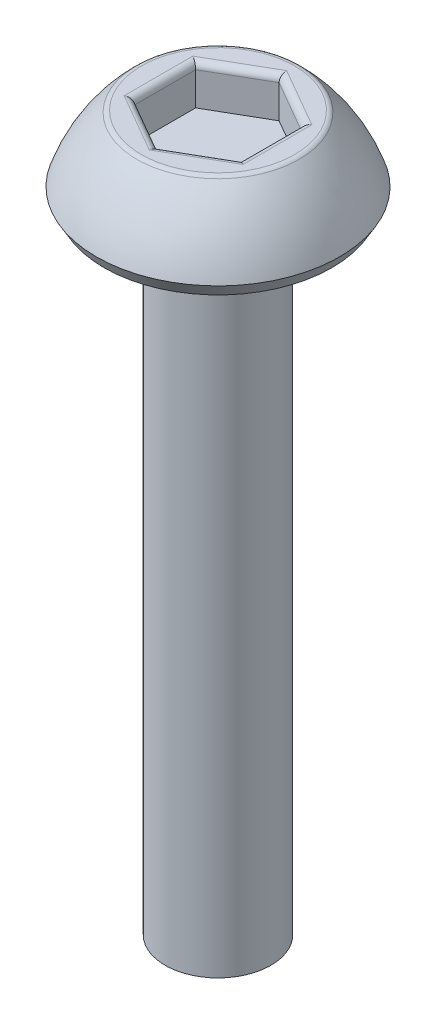
from build123d import *

# Parameters (mm, degrees)
CUT_EXTRUDE1_DEPTH = 0.75
FILLET1_R          = 0.125


with BuildPart() as part:
    # Sketch1 → Revolve1 (revolve)
    with BuildSketch(Plane(origin=(0, 0, 0), x_dir=(0, 0, -1), z_dir=(1, 0, 0))):
        with BuildLine():
            Line((0, 1.5), (-1.5, 1.5))
            ThreePointArc((-1.5, 1.5), (-1.978515811, 0.925250119), (-2.3, 0.25))
            Line((-2.3, 0.25), (-2.155662433, 0))
            Line((-2.155662433, 0), (-1, 0))
            Line((-1, 0), (-1, -12))
            Line((-1, -12), (0, -12))
            Line((0, -12), (0, 1.5))
        make_face()
    revolve(axis=Axis((0, -12, 0), (0, 1, 0)))

    # Sketch2 → Cut-Extrude1 (cut)
    with BuildSketch(Plane(origin=(0, 1.5, 0), x_dir=(1, 0, 0), z_dir=(0, 1, 0))):
        Polygon((0, 1.154700538), (-1, 0.577350269), (-1, -0.577350269), (0, -1.154700538), (1, -0.577350269), (1, 0.577350269), align=None)
    extrude(amount=-CUT_EXTRUDE1_DEPTH, mode=Mode.SUBTRACT)

    # Fillet1
    fillet1_edges = [part.edges().sort_by_distance(p)[0] for p in [
        (0.5, 1.5, -0.866025404),
        (-0.5, 1.5, -0.866025404),
        (-1, 1.5, 0),
        (-0.5, 1.5, 0.866025404),
        (0.5, 1.5, 0.866025404),
        (1, 1.5, 0),
        (0, 1.5, -1.5),
    ]]
    fillet(fillet1_edges, radius=FILLET1_R)


solid = part.part
